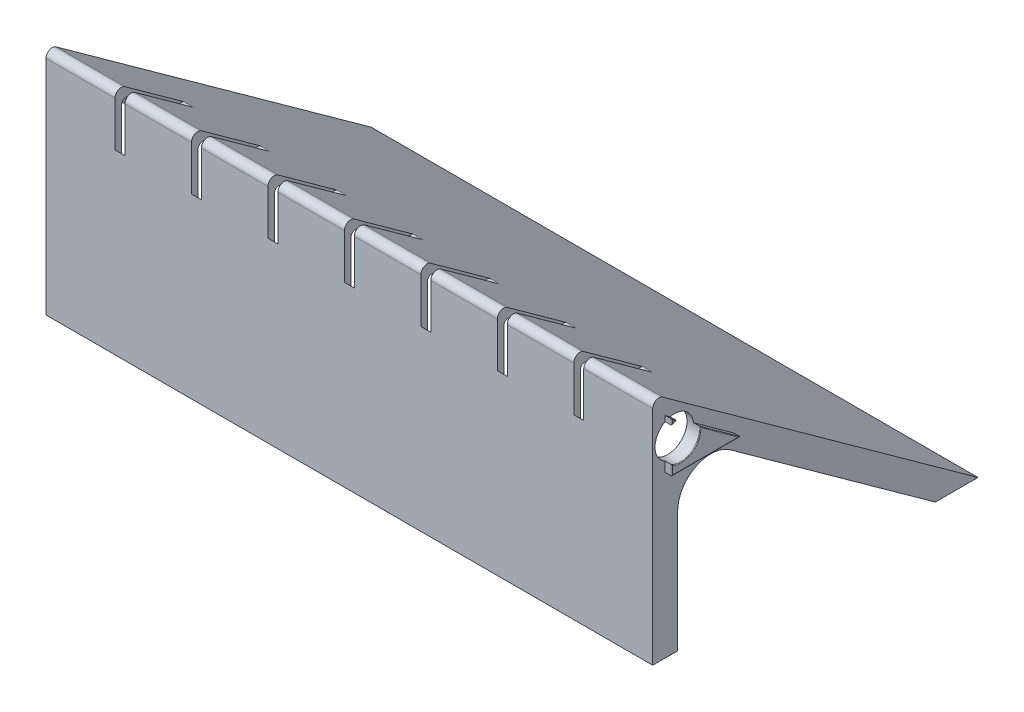
from build123d import *
from build123d.topology import SkipClean

# Parameters (mm, degrees)
BOSS_EXTRUDE1_DEPTH    = 115.8875
SHELL1_T               = -2.54
FILLET7_R              = 1.5875
FILLET6_R              = 3.175
CUT_EXTRUDE1_DEPTH     = 1.905
FILLET8_R              = 1.5875
LPATTERN1_COUNT        = 4
LPATTERN1_PITCH        = 29.21
FILLET8_OF_LPATTERN1_R = 1.5875
LPATTERN2_COUNT        = 4
LPATTERN2_PITCH        = 29.21
FILLET8_OF_LPATTERN2_R = 1.5875
BOSS_EXTRUDE2_DEPTH    = 2.54
SKETCH5_R              = 7.385
CUT_EXTRUDE2_DEPTH     = 4.8
FILLET4_R              = 0.254
FILLET5_R              = 0.254
SKETCH6_R              = 3.2385
CUT_EXTRUDE3_DEPTH     = 278.093208583


with BuildPart() as part:
    # Sketch1 → Boss-Extrude1 (new, symmetric)
    with BuildSketch(Plane(origin=(0, 0, 0), x_dir=(0, 0, -1), z_dir=(1, 0, 0))):
        with BuildLine():
            Line((0, 0), (0, 84.901644013))
            ThreePointArc((0, 84.901644013), (1.29607654, 87.021254856), (3.773438424, 86.833524691))
            Line((3.773438424, 86.833524691), (124.268628317, 0))
            Line((124.268628317, 0), (107.976719942, 0))
            Line((107.976719942, 0), (29.650004929, 56.445280082))
            ThreePointArc((29.650004929, 56.445280082), (16.437408213, 57.446507626), (9.525, 46.141916466))
            Line((9.525, 46.141916466), (9.525, 0))
            Line((9.525, 0), (0, 0))
        make_face()
    extrude(amount=BOSS_EXTRUDE1_DEPTH, both=True)

    # Shell1
    shell1_openings = [part.faces().sort_by_distance(p)[0] for p in [
        (0, 28.222640041, -68.813362436),
        (0, 57.446507626, -16.437408213),
        (0, 23.070958233, -9.525),
    ]]
    offset(amount=SHELL1_T, openings=shell1_openings, kind=Kind.INTERSECTION)

    # Fillet7
    fillet7_edges = [part.edges().sort_by_distance(p)[0] for p in [
        (0, 84.591566193, -2.54),
    ]]
    fillet(fillet7_edges, radius=FILLET7_R)

    # Fillet6
    fillet6_edges = [part.edges().sort_by_distance(p)[0] for p in [
        (0, 2.54, -116.399469423),
    ]]
    fillet(fillet6_edges, radius=FILLET6_R)

    # Sketch3 → Cut-Extrude1 (cut, symmetric)
    with BuildSketch(Plane(origin=(0, -2.413, -15.875), x_dir=(0, 0, 1), z_dir=(-1, 0, 0))):
        with BuildLine():
            Line((-7.926699104, 71.361902399), (-8.271161087, 70.883874176))
            ThreePointArc((-8.271161087, 70.883874176), (3.476459724, 61.284711128), (15.828327064, 70.09276989))
            ThreePointArc((15.828327064, 70.09276989), (15.901291869, 70.288577921), (15.970972384, 70.485578616))
            Line((15.970972384, 70.485578616), (17.531294258, 75.017082374))
            Line((17.531294258, 75.017082374), (17.531294258, 94.003784079))
            Line((17.531294258, 94.003784079), (-8.281098949, 75.779023692))
            ThreePointArc((-8.281098949, 75.779023692), (-8.301253168, 73.554628688), (-7.926699104, 71.361902399))
        make_face()
    cut_extrude1 = extrude(amount=CUT_EXTRUDE1_DEPTH, both=True, mode=Mode.SUBTRACT)

    # Fillet8
    fillet8_edges = [part.edges().sort_by_distance(p)[0] for p in [
        (0, 72.101660209, -24.21622034),
    ]]
    fillet(fillet8_edges, radius=FILLET8_R)

    # LPattern1: Cut-Extrude1 ×4
    with Locations(*[(i * LPATTERN1_PITCH, 0, 0) for i in range(1, LPATTERN1_COUNT)]):
        add(cut_extrude1, mode=Mode.SUBTRACT)

    # Fillet8 of LPattern1
    fillet8_of_lpattern1_edges = [part.edges().sort_by_distance(p)[0] for p in [
        (29.21, 72.101660209, -24.21622034),
        (58.42, 72.101660209, -24.21622034),
        (87.63, 72.101660209, -24.21622034),
    ]]
    fillet(fillet8_of_lpattern1_edges, radius=FILLET8_OF_LPATTERN1_R)

    # LPattern2: Cut-Extrude1 ×4
    with Locations(*[(-i * LPATTERN2_PITCH, 0, 0) for i in range(1, LPATTERN2_COUNT)]):
        add(cut_extrude1, mode=Mode.SUBTRACT)

    # Fillet8 of LPattern2
    fillet8_of_lpattern2_edges = [part.edges().sort_by_distance(p)[0] for p in [
        (-29.21, 72.101660209, -24.21622034),
        (-58.42, 72.101660209, -24.21622034),
        (-87.63, 72.101660209, -24.21622034),
    ]]
    fillet(fillet8_of_lpattern2_edges, radius=FILLET8_OF_LPATTERN2_R)

    # Sketch4 → Boss-Extrude2 (add)
    with BuildSketch(Plane(origin=(115.8875, 0, 0), x_dir=(0, 0, -1), z_dir=(1, 0, 0))):
        with BuildLine():
            Line((4.7625, 80.250476708), (4.7625, 78.187860591))
            ThreePointArc((4.7625, 78.187860591), (5.681515336, 78.604108973), (6.648686934, 78.891216974))
            Line((6.648686934, 78.891216974), (4.7625, 80.250476708))
        make_face()
        with BuildLine():
            Line((30.872562622, 61.434549123), (15.608650064, 72.434318733))
            ThreePointArc((15.608650064, 72.434318733), (12.367009719, 65.545693058), (4.7625, 65.181237654))
            Line((4.7625, 65.181237654), (4.7625, 61.434549123))
            Line((4.7625, 61.434549123), (30.872562622, 61.434549123))
        make_face()
    extrude(amount=BOSS_EXTRUDE2_DEPTH)

    # Sketch5 → Cut-Extrude2 (cut)
    with SkipClean():  # the faces are left unmerged after this step: merging them gives an invalid solid
        with BuildSketch(Plane(origin=(115.8875, 0, 0), x_dir=(0, 0, -1), z_dir=(1, 0, 0))):
            with Locations(Location((8.26180921, 71.684549123, 0), (0, 0, 219.214186209))):
                Circle(SKETCH5_R)
        extrude(amount=-CUT_EXTRUDE2_DEPTH, mode=Mode.SUBTRACT)

    # Fillet4
    fillet4_edges = [part.edges().sort_by_distance(p)[0] for p in [
        (118.4275, 79.570846841, -5.705593467),
        (118.4275, 79.219168649, -4.7625),
        (118.4275, 78.604108973, -5.681515336),
    ]]
    fillet(fillet4_edges, radius=FILLET4_R)

    # Fillet5
    fillet5_edges = [part.edges().sort_by_distance(p)[0] for p in [
        (118.4275, 61.434549123, -17.817531311),
        (118.4275, 66.934433928, -23.240606343),
        (118.4275, 65.545693058, -12.367009719),
        (118.4275, 63.307893389, -4.7625),
    ]]
    fillet(fillet5_edges, radius=FILLET5_R)

    # Sketch6 → Cut-Extrude3 (cut, through all)
    with BuildSketch(Plane(origin=(-113.3475, 0, 0), x_dir=(0, 0, -1), z_dir=(1, 0, 0))):
        with Locations((8.26180921, 71.684549123)):
            Circle(SKETCH6_R)
    extrude(amount=-CUT_EXTRUDE3_DEPTH, mode=Mode.SUBTRACT)


solid = part.part
